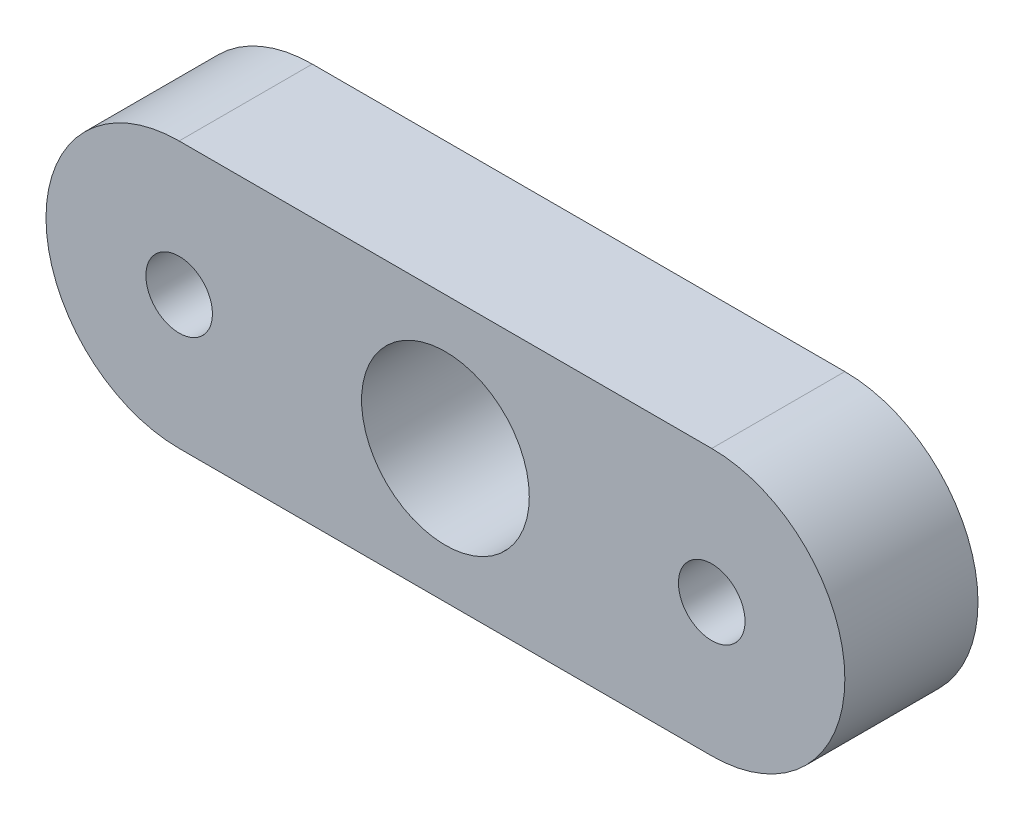
from build123d import *

# Parameters (mm, degrees)
SKETCH2_R           = 2
SKETCH2_R_2         = 0.79375
BOSS_EXTRUDE1_DEPTH = 3.175


with BuildPart() as part:
    # Sketch2 → Boss-Extrude1 (new body)
    with BuildSketch(Plane.XY):
        with BuildLine():
            Line((-6.35, 3.175), (6.35, 3.175))
            ThreePointArc((6.35, 3.175), (9.525, 0), (6.35, -3.175))
            Line((6.35, -3.175), (-6.35, -3.175))
            ThreePointArc((-6.35, -3.175), (-9.525, 0), (-6.35, 3.175))
        make_face()
        Circle(SKETCH2_R, mode=Mode.SUBTRACT)
        with Locations((-6.35, 0)):
            Circle(SKETCH2_R_2, mode=Mode.SUBTRACT)
        with Locations((6.35, 0)):
            Circle(SKETCH2_R_2, mode=Mode.SUBTRACT)
    extrude(amount=BOSS_EXTRUDE1_DEPTH)


solid = part.part
